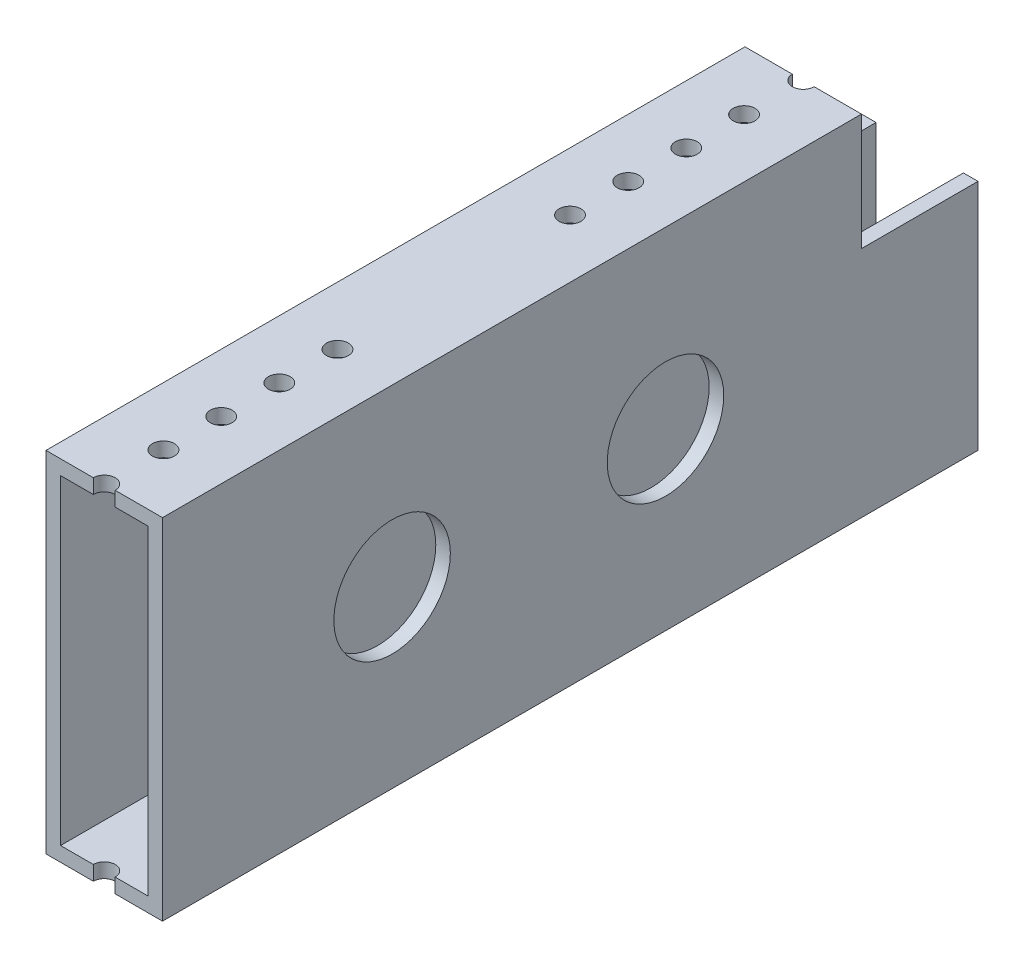
from build123d import *

# Parameters (mm, degrees)
SKETCH1_W           = 25.4
SKETCH1_H           = 76.2
BOSS_EXTRUDE1_DEPTH = 88.9
SHELL1_T            = -3.175
SKETCH2_W           = 25.4
SKETCH2_H           = 25.4
CUT_EXTRUDE1_DEPTH  = 26.4
SKETCH3_R           = 2.38125
CUT_EXTRUDE2_DEPTH  = 77.2
SKETCH5_R           = 12.7
CUT_EXTRUDE3_DEPTH  = 26.4


with BuildPart() as part:
    # Sketch1 → Boss-Extrude1 (new body, symmetric)
    with BuildSketch(Plane.XY):
        Rectangle(SKETCH1_W, SKETCH1_H)
    extrude(amount=BOSS_EXTRUDE1_DEPTH, both=True)

    # Shell1
    shell1_openings = [part.faces().sort_by_distance(p)[0] for p in [
        (0, 0, 88.9),
        (0, 0, -88.9),
    ]]
    offset(amount=SHELL1_T, openings=shell1_openings, kind=Kind.INTERSECTION)

    # Sketch2 → Cut-Extrude1 (cut, through all)
    with BuildSketch(Plane.ZY.offset(12.7)):
        with Locations((-76.2, 25.4)):
            Rectangle(SKETCH2_W, SKETCH2_H)
    extrude(amount=-CUT_EXTRUDE1_DEPTH, mode=Mode.SUBTRACT)

    # Sketch3 → Cut-Extrude2 (cut, through all)
    with BuildSketch(Plane(origin=(0, 38.1, 0), x_dir=(1, 0, 0), z_dir=(0, 1, 0))):
        with Locations((0, -88.9)):
            Circle(SKETCH3_R)
        with Locations((0, -75.995900078)):
            Circle(SKETCH3_R)
        with Locations((0, -63.397337518)):
            Circle(SKETCH3_R)
        with Locations((0, -50.731481722)):
            Circle(SKETCH3_R)
        with Locations((0, -38.048590908)):
            Circle(SKETCH3_R)
        with Locations((0, 63.5)):
            Circle(SKETCH3_R)
        with Locations((0, 12.648590908)):
            Circle(SKETCH3_R)
        with Locations((0, 25.331481722)):
            Circle(SKETCH3_R)
        with Locations((0, 37.997337518)):
            Circle(SKETCH3_R)
        with Locations((0, 50.595900078)):
            Circle(SKETCH3_R)
    extrude(amount=-CUT_EXTRUDE2_DEPTH, mode=Mode.SUBTRACT)

    # Sketch5 → Cut-Extrude3 (cut, through all)
    with BuildSketch(Plane(origin=(12.7, 0, 0), x_dir=(0, 0, -1), z_dir=(1, 0, 0))):
        with Locations((20.760556689, 0)):
            Circle(SKETCH5_R)
        with Locations((-38.84233187, 0)):
            Circle(SKETCH5_R)
    extrude(amount=-CUT_EXTRUDE3_DEPTH, mode=Mode.SUBTRACT)


solid = part.part
